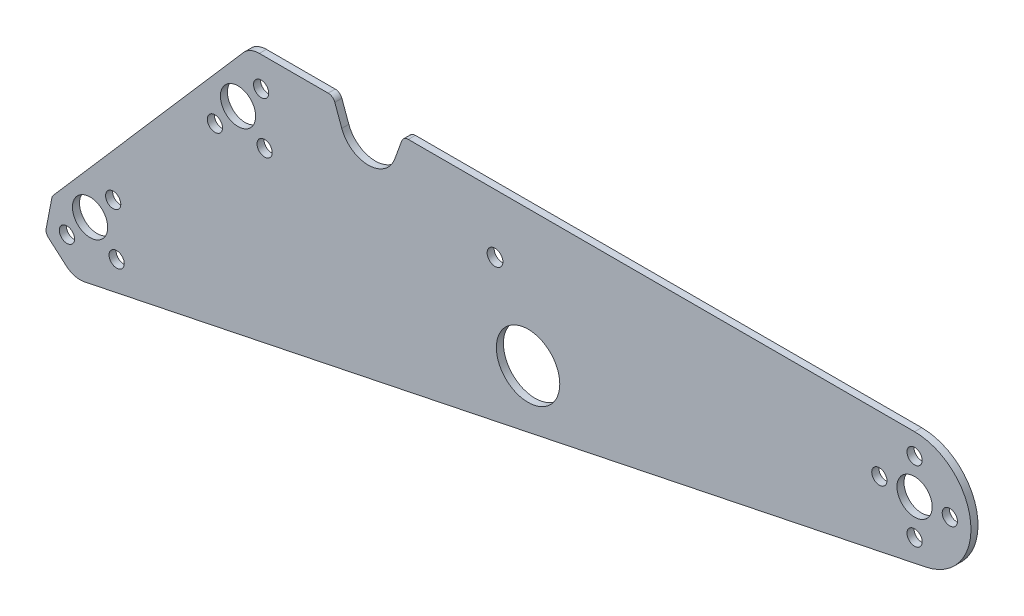
from build123d import *

# Parameters (mm, degrees)
SKETCH1_R           = 7.9375
SKETCH1_R_2         = 3.429
SKETCH1_R_3         = 14.2875
SKETCH1_R_4         = 3.556
BOSS_EXTRUDE1_DEPTH = 3.175


with BuildPart() as part:
    # Sketch1 → Boss-Extrude1 (new body)
    with BuildSketch(Plane.XY):
        with BuildLine():
            Line((304.8, 25.4), (76.724364717, 25.4))
            ThreePointArc((76.724364717, 25.4), (74.903259532, 24.825807741), (73.740840646, 23.310913955))
            Line((73.740840646, 23.310913955), (70.609033369, 14.70634418))
            ThreePointArc((70.609033369, 14.70634418), (58.674937085, 6.35), (46.740840801, 14.70634418))
            Line((46.740840801, 14.70634418), (43.609033524, 23.310913955))
            ThreePointArc((43.609033524, 23.310913955), (42.446614639, 24.825807741), (40.625509453, 25.4))
            Line((40.625509453, 25.4), (9.593010709, 25.4))
            ThreePointArc((9.593010709, 25.4), (5.643057573, 24.542381105), (2.404401957, 22.123962251))
            Line((2.404401957, 22.123962251), (-83.157756356, -76.304041526))
            ThreePointArc((-83.157756356, -76.304041526), (-83.615224536, -76.995200552), (-83.878219746, -77.781210383))
            Line((-83.878219746, -77.781210383), (-86.451909051, -91.021694031))
            ThreePointArc((-86.451909051, -91.021694031), (-86.337264221, -92.661191482), (-85.418230161, -94.023715509))
            Line((-85.418230161, -94.023715509), (-77.389837916, -101.002690413))
            ThreePointArc((-77.389837916, -101.002690413), (-73.552808487, -103.028646494), (-69.21525712, -103.142405102))
            Line((-69.21525712, -103.142405102), (309.934982787, -24.875529176))
            ThreePointArc((309.934982787, -24.875529176), (330.068542113, 2.580848594), (304.8, 25.4))
        make_face()
        with Locations((304.8, 0)):
            Circle(SKETCH1_R, mode=Mode.SUBTRACT)
        Circle(SKETCH1_R, mode=Mode.SUBTRACT)
        with Locations((-66.655597345, -76.678493351)):
            Circle(SKETCH1_R, mode=Mode.SUBTRACT)
        with Locations((304.8, 15.875)):
            Circle(SKETCH1_R_2, mode=Mode.SUBTRACT)
        with Locations((320.675, 0)):
            Circle(SKETCH1_R_2, mode=Mode.SUBTRACT)
        with Locations((304.8, -15.875)):
            Circle(SKETCH1_R_2, mode=Mode.SUBTRACT)
        with Locations((288.925, 0)):
            Circle(SKETCH1_R_2, mode=Mode.SUBTRACT)
        with Locations((-56.24066026, -64.697478765)):
            Circle(SKETCH1_R_2, mode=Mode.SUBTRACT)
        with Locations((-54.674582759, -87.093430436)):
            Circle(SKETCH1_R_2, mode=Mode.SUBTRACT)
        with Locations((-77.070534431, -88.659507937)):
            Circle(SKETCH1_R_2, mode=Mode.SUBTRACT)
        with Locations((-10.414937085, -11.981014586)):
            Circle(SKETCH1_R_2, mode=Mode.SUBTRACT)
        with Locations((11.981014586, -10.414937085)):
            Circle(SKETCH1_R_2, mode=Mode.SUBTRACT)
        with Locations((10.414937085, 11.981014586)):
            Circle(SKETCH1_R_2, mode=Mode.SUBTRACT)
        with Locations((130.671295769, -35.944879509)):
            Circle(SKETCH1_R_3, mode=Mode.SUBTRACT)
        with Locations((115.786625943, -1.087398892)):
            Circle(SKETCH1_R_4, mode=Mode.SUBTRACT)
    extrude(amount=BOSS_EXTRUDE1_DEPTH)


solid = part.part
